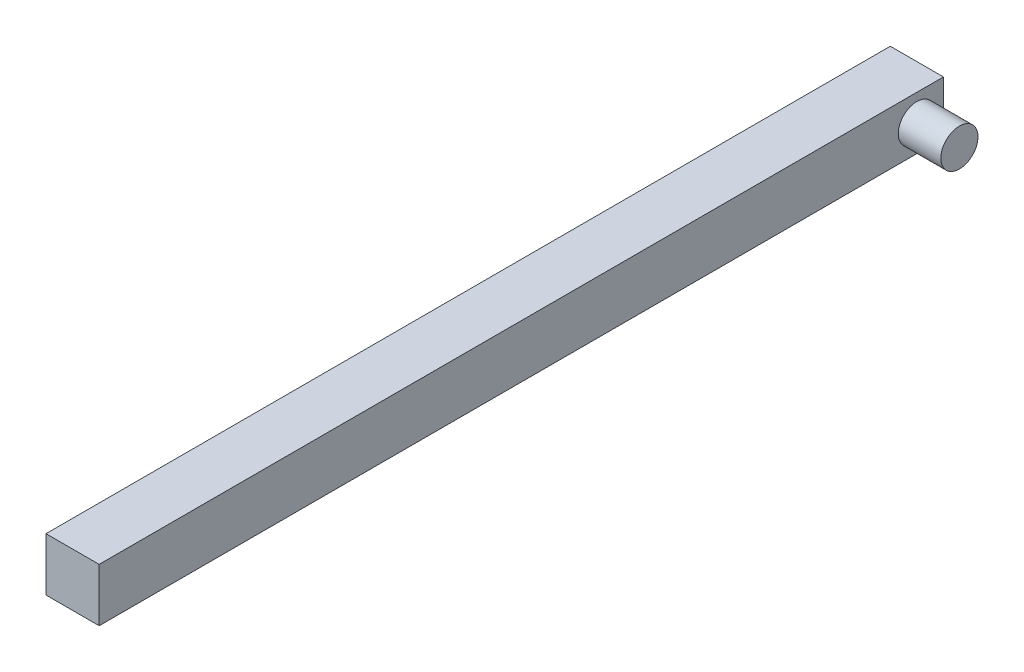
from build123d import *

# Parameters (mm, degrees)
SKETCH2_W           = 10
SKETCH2_H           = 10
BOSS_EXTRUDE1_DEPTH = 158.8
SKETCH3_R           = 3.5
BOSS_EXTRUDE2_DEPTH = 8
SKETCH4_W           = 15
SKETCH4_H           = 27.94
BOSS_EXTRUDE4_DEPTH = 4
SKETCH5_W           = 2.25448465
SKETCH5_H           = 27.94
BOSS_EXTRUDE5_DEPTH = 4
SKETCH6_R           = 1.5
CUT_EXTRUDE1_DEPTH  = 40
SKETCH7_W           = 15
SKETCH7_H           = 27.94
CUT_EXTRUDE2_DEPTH  = 8


with BuildPart() as part:
    # Sketch2 → Boss-Extrude1 (new body)
    with BuildSketch(Plane.XY):
        with Locations((5, 5)):
            Rectangle(SKETCH2_W, SKETCH2_H)
    extrude(amount=BOSS_EXTRUDE1_DEPTH)

    # Sketch3 → Boss-Extrude2 (add)
    with BuildSketch(Plane(origin=(10, 0, 0), x_dir=(0, 0, -1), z_dir=(1, 0, 0))):
        with Locations((-5, 5)):
            Circle(SKETCH3_R)
    extrude(amount=BOSS_EXTRUDE2_DEPTH)

    # Sketch4 → Boss-Extrude4 (add)
    with BuildSketch(Plane.XY.offset(158.8)):
        with Locations((7.5, 5)):
            Rectangle(SKETCH4_W, SKETCH4_H)
    extrude(amount=BOSS_EXTRUDE4_DEPTH)

    # Sketch5 → Boss-Extrude5 (add)
    with BuildSketch(Plane.XY.offset(162.8)):
        with Locations((13.872757675, 5)):
            Rectangle(SKETCH5_W, SKETCH5_H)
    extrude(amount=BOSS_EXTRUDE5_DEPTH)

    # Sketch6 → Cut-Extrude1 (cut)
    with BuildSketch(Plane.ZY.offset(-12.74551535)):
        with Locations((165.086, 16.64426)):
            Circle(SKETCH6_R)
        with Locations((165.086, -6.645)):
            Circle(SKETCH6_R)
    extrude(amount=-CUT_EXTRUDE1_DEPTH, mode=Mode.SUBTRACT)

    # Sketch7 → Cut-Extrude2 (cut)
    with BuildSketch(Plane.XY.offset(166.8)):
        with Locations((7.5, 5)):
            Rectangle(SKETCH7_W, SKETCH7_H)
    extrude(amount=-CUT_EXTRUDE2_DEPTH, mode=Mode.SUBTRACT)


solid = part.part
